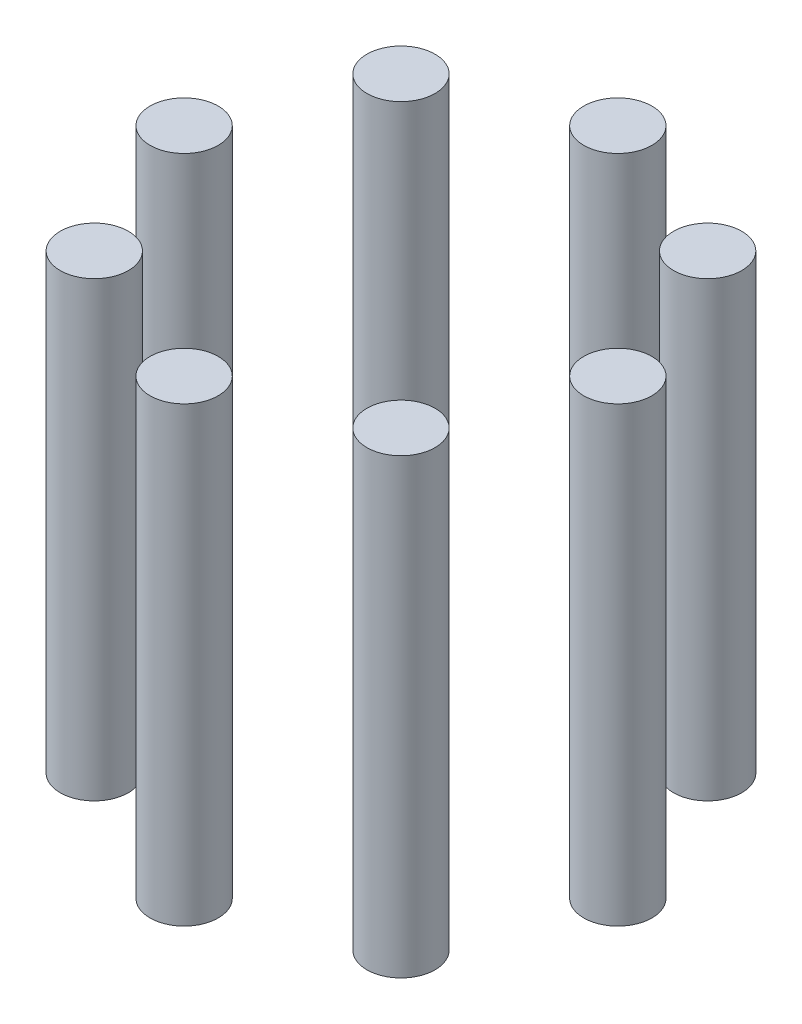
from build123d import *

# Parameters (mm, degrees)
SKETCH1_R             = 5.5
BOSS_EXTRUDE1_DEPTH   = 73
BOSS_EXTRUDE1_2_DEPTH = 73
BOSS_EXTRUDE1_3_DEPTH = 73
BOSS_EXTRUDE1_4_DEPTH = 73
BOSS_EXTRUDE1_5_DEPTH = 73
BOSS_EXTRUDE1_6_DEPTH = 73
BOSS_EXTRUDE1_7_DEPTH = 73
BOSS_EXTRUDE1_8_DEPTH = 73


with BuildPart() as part:
    # Sketch1 → Boss-Extrude1 (new body)
    with BuildSketch(Plane(origin=(0, 0, 0), x_dir=(1, 0, 0), z_dir=(0, 1, 0))):
        with Locations((-35, 0)):
            Circle(SKETCH1_R)
    extrude(amount=BOSS_EXTRUDE1_DEPTH)


with BuildPart() as body_2:
    # Sketch1 → Boss-Extrude1 2 (new body)
    with BuildSketch(Plane(origin=(0, 0, 0), x_dir=(1, 0, 0), z_dir=(0, 1, 0))):
        with Locations((-24.748737342, 24.748737342)):
            Circle(SKETCH1_R)
    extrude(amount=BOSS_EXTRUDE1_2_DEPTH)


with BuildPart() as body_3:
    # Sketch1 → Boss-Extrude1 3 (new body)
    with BuildSketch(Plane(origin=(0, 0, 0), x_dir=(1, 0, 0), z_dir=(0, 1, 0))):
        with Locations((0, 35)):
            Circle(SKETCH1_R)
    extrude(amount=BOSS_EXTRUDE1_3_DEPTH)


with BuildPart() as body_4:
    # Sketch1 → Boss-Extrude1 4 (new body)
    with BuildSketch(Plane(origin=(0, 0, 0), x_dir=(1, 0, 0), z_dir=(0, 1, 0))):
        with Locations((24.748737342, 24.748737342)):
            Circle(SKETCH1_R)
    extrude(amount=BOSS_EXTRUDE1_4_DEPTH)


with BuildPart() as body_5:
    # Sketch1 → Boss-Extrude1 5 (new body)
    with BuildSketch(Plane(origin=(0, 0, 0), x_dir=(1, 0, 0), z_dir=(0, 1, 0))):
        with Locations((35, 0)):
            Circle(SKETCH1_R)
    extrude(amount=BOSS_EXTRUDE1_5_DEPTH)


with BuildPart() as body_6:
    # Sketch1 → Boss-Extrude1 6 (new body)
    with BuildSketch(Plane(origin=(0, 0, 0), x_dir=(1, 0, 0), z_dir=(0, 1, 0))):
        with Locations((24.748737342, -24.748737342)):
            Circle(SKETCH1_R)
    extrude(amount=BOSS_EXTRUDE1_6_DEPTH)


with BuildPart() as body_7:
    # Sketch1 → Boss-Extrude1 7 (new body)
    with BuildSketch(Plane(origin=(0, 0, 0), x_dir=(1, 0, 0), z_dir=(0, 1, 0))):
        with Locations((0, -35)):
            Circle(SKETCH1_R)
    extrude(amount=BOSS_EXTRUDE1_7_DEPTH)


with BuildPart() as body_8:
    # Sketch1 → Boss-Extrude1 8 (new body)
    with BuildSketch(Plane(origin=(0, 0, 0), x_dir=(1, 0, 0), z_dir=(0, 1, 0))):
        with Locations((-24.748737342, -24.748737342)):
            Circle(SKETCH1_R)
    extrude(amount=BOSS_EXTRUDE1_8_DEPTH)


solid = Compound([part.part, body_2.part, body_3.part, body_4.part, body_5.part, body_6.part, body_7.part, body_8.part])
